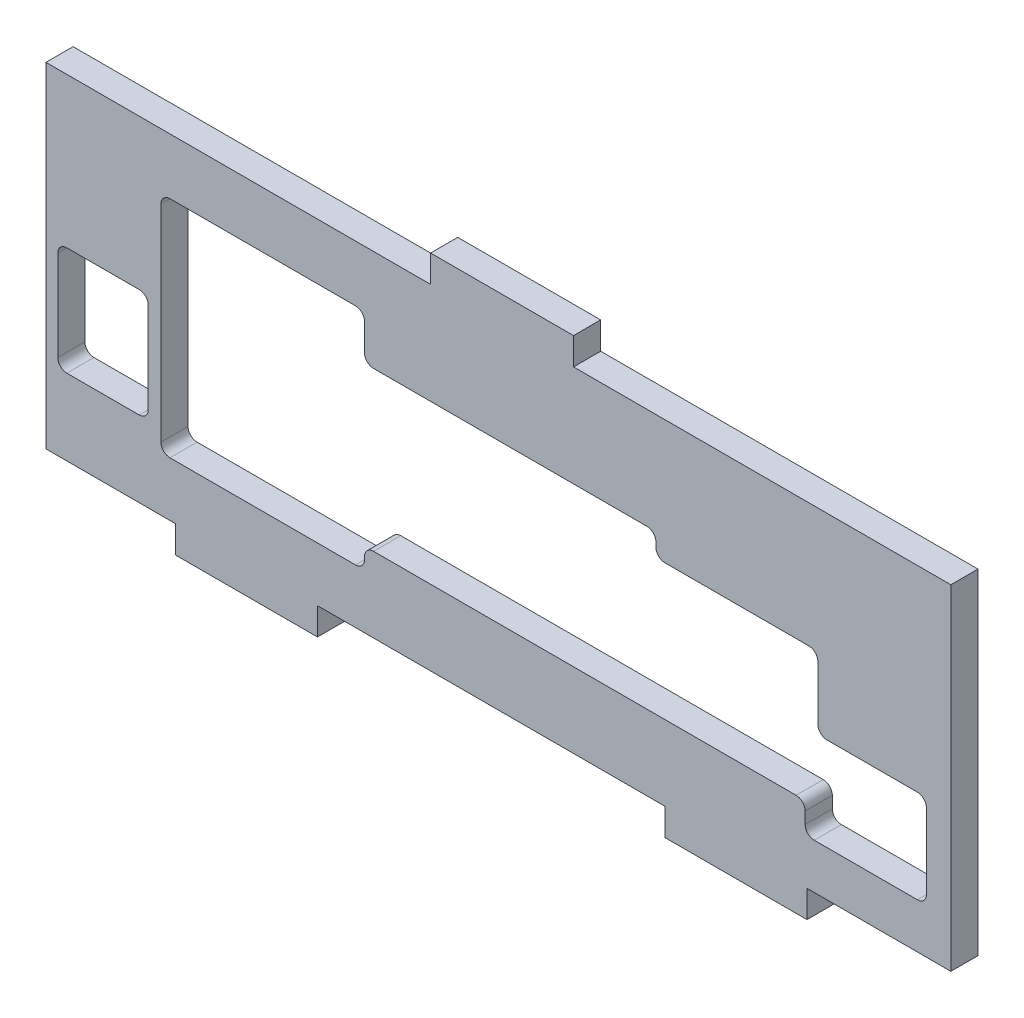
from build123d import *

# Parameters (mm, degrees)
SALIENTE_EXTRUIR1_DEPTH = 3


with BuildPart() as part:
    # Croquis1 → Saliente-Extruir1 (new body)
    with BuildSketch(Plane.XY):
        Polygon((8.3, 21.5), (-7.5, 21.5), (-7.5, 18.5), (-50, 18.5), (-50, -18.5), (-35.7, -18.5), (-35.7, -21.5), (-20, -21.5), (-20, -18.5), (18.4, -18.5), (18.4, -21.5), (34.1, -21.5), (34.1, -18.5), (50, -18.5), (50, 18.5), (8.3, 18.5), align=None)
        with BuildLine():
            ThreePointArc((-48.7, 0.9), (-48.407106781, 1.607106781), (-47.7, 1.9))
            Line((-47.7, 1.9), (-39.7, 1.9))
            ThreePointArc((-39.7, 1.9), (-38.992893219, 1.607106781), (-38.7, 0.9))
            Line((-38.7, 0.9), (-38.7, -9.1))
            ThreePointArc((-38.7, -9.1), (-38.992893219, -9.807106781), (-39.7, -10.1))
            Line((-39.7, -10.1), (-47.7, -10.1))
            ThreePointArc((-47.7, -10.1), (-48.407106781, -9.807106781), (-48.7, -9.1))
            Line((-48.7, -9.1), (-48.7, 0.9))
        make_face(mode=Mode.SUBTRACT)
        with BuildLine():
            ThreePointArc((-13.8, -10.2), (-14.507106781, -10.492893219), (-14.8, -11.2))
            Line((-14.8, -11.2), (-14.8, -11.5))
            ThreePointArc((-14.8, -11.5), (-15.092893219, -12.207106781), (-15.8, -12.5))
            Line((-15.8, -12.5), (-36.3, -12.5))
            ThreePointArc((-36.3, -12.5), (-37.007106781, -12.207106781), (-37.3, -11.5))
            Line((-37.3, -11.5), (-37.3, 11.3))
            ThreePointArc((-37.3, 11.3), (-37.007106781, 12.007106781), (-36.3, 12.3))
            Line((-36.3, 12.3), (-15.8, 12.3))
            ThreePointArc((-15.8, 12.3), (-15.092893219, 12.007106781), (-14.8, 11.3))
            Line((-14.8, 11.3), (-14.8, 8.3))
            ThreePointArc((-14.8, 8.3), (-14.507106781, 7.592893219), (-13.8, 7.3))
            Line((-13.8, 7.3), (16.4, 7.3))
            ThreePointArc((16.4, 7.3), (17.107106781, 7.007106781), (17.4, 6.3))
            Line((17.4, 6.3), (17.4, 5.8))
            ThreePointArc((17.4, 5.8), (17.692893219, 5.092893219), (18.4, 4.8))
            Line((18.4, 4.8), (34.3, 4.8))
            ThreePointArc((34.3, 4.8), (35.007106781, 4.507106781), (35.3, 3.8))
            Line((35.3, 3.8), (35.3, -2.2))
            ThreePointArc((35.3, -2.2), (35.592893219, -2.907106781), (36.3, -3.2))
            Line((36.3, -3.2), (46.3, -3.2))
            ThreePointArc((46.3, -3.2), (47.007106781, -3.492893219), (47.3, -4.2))
            Line((47.3, -4.2), (47.3, -12.5))
            ThreePointArc((47.3, -12.5), (47.007106781, -13.207106781), (46.3, -13.5))
            Line((46.3, -13.5), (34.9, -13.5))
            ThreePointArc((34.9, -13.5), (34.192893219, -13.207106781), (33.9, -12.5))
            Line((33.9, -12.5), (33.9, -11.2))
            ThreePointArc((33.9, -11.2), (33.607106781, -10.492893219), (32.9, -10.2))
            Line((32.9, -10.2), (17.4, -10.2))
            Line((17.4, -10.2), (-13.8, -10.2))
        make_face(mode=Mode.SUBTRACT)
    extrude(amount=SALIENTE_EXTRUIR1_DEPTH)


solid = part.part
